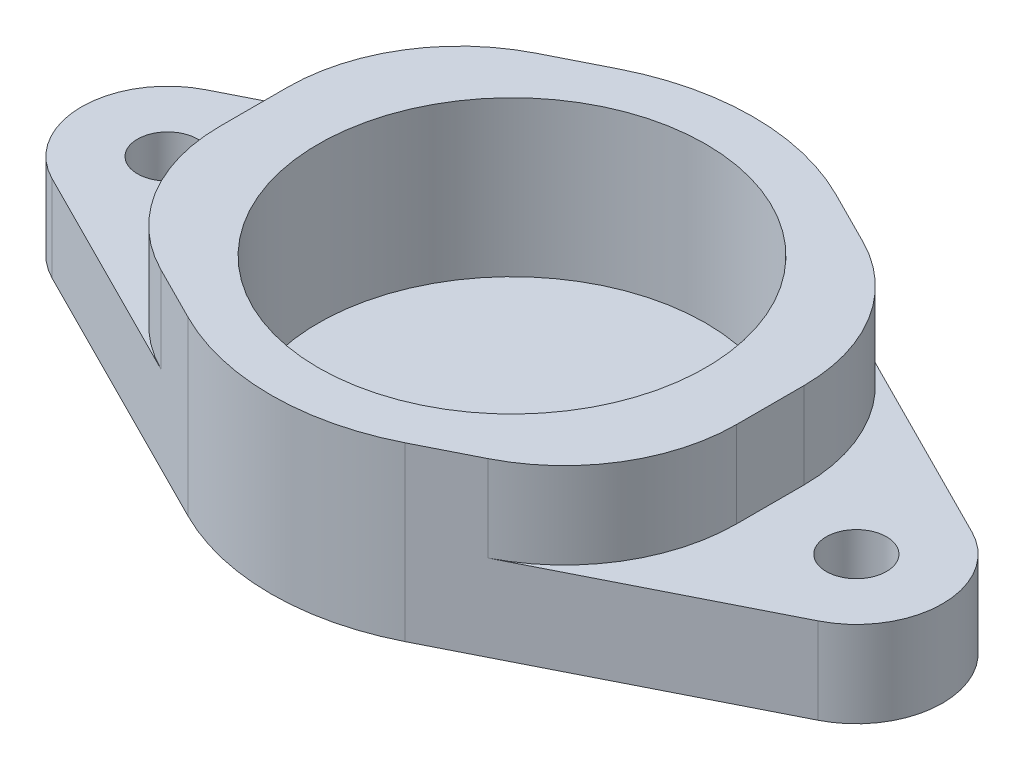
from build123d import *

# Parameters (mm, degrees)
SKETCH2_R               = 1.75
BOSS_EXTRUDE1_DEPTH     = 10
SKETCH3_R               = 11.25
CUT_EXTRUDE1_DEPTH      = 9
SKETCH4_W               = 10
SKETCH4_H               = 5
CUT_EXTRUDE2_DEPTH      = 15
CUT_EXTRUDE2_DEPTH_BACK = 15
FILLET1_R               = 10


with BuildPart() as part:
    # Sketch2 → Boss-Extrude1 (new body)
    with BuildSketch(Plane(origin=(0, 0, 0), x_dir=(1, 0, 0), z_dir=(0, 1, 0))):
        with BuildLine():
            Line((-22.25, 4.465142775), (-6.3, 12.50239977))
            ThreePointArc((-6.3, 12.50239977), (0, 14), (6.3, 12.50239977))
            Line((6.3, 12.50239977), (22.25, 4.465142775))
            ThreePointArc((22.25, 4.465142775), (25, 0), (22.25, -4.465142775))
            Line((22.25, -4.465142775), (6.3, -12.50239977))
            ThreePointArc((6.3, -12.50239977), (0, -14), (-6.3, -12.50239977))
            Line((-6.3, -12.50239977), (-22.25, -4.465142775))
            ThreePointArc((-22.25, -4.465142775), (-25, 0), (-22.25, 4.465142775))
        make_face()
        with Locations((-20, 0)):
            Circle(SKETCH2_R, mode=Mode.SUBTRACT)
        with Locations((20, 0)):
            Circle(SKETCH2_R, mode=Mode.SUBTRACT)
    extrude(amount=BOSS_EXTRUDE1_DEPTH)

    # Sketch3 → Cut-Extrude1 (cut)
    with BuildSketch(Plane(origin=(0, 10, 0), x_dir=(1, 0, 0), z_dir=(0, 1, 0))):
        Circle(SKETCH3_R)
    extrude(amount=-CUT_EXTRUDE1_DEPTH, mode=Mode.SUBTRACT)

    # Sketch4 → Cut-Extrude2 (cut, two sides)
    with BuildSketch(Plane.XY) as cut_extrude2_sk:
        with Locations((-20, 7.5)):
            Rectangle(SKETCH4_W, SKETCH4_H)
        with Locations((20, 7.5)):
            Rectangle(SKETCH4_W, SKETCH4_H)
    extrude(amount=CUT_EXTRUDE2_DEPTH, mode=Mode.SUBTRACT)
    extrude(cut_extrude2_sk.sketch, amount=-CUT_EXTRUDE2_DEPTH_BACK, mode=Mode.SUBTRACT)

    # Fillet1
    fillet1_edges = [part.edges().sort_by_distance(p)[0] for p in [
        (-15, 7.5, -8.118441409),
        (15, 7.5, -8.118441409),
        (-15, 7.5, 8.118441409),
        (15, 7.5, 8.118441409),
    ]]
    fillet(fillet1_edges, radius=FILLET1_R)


solid = part.part
